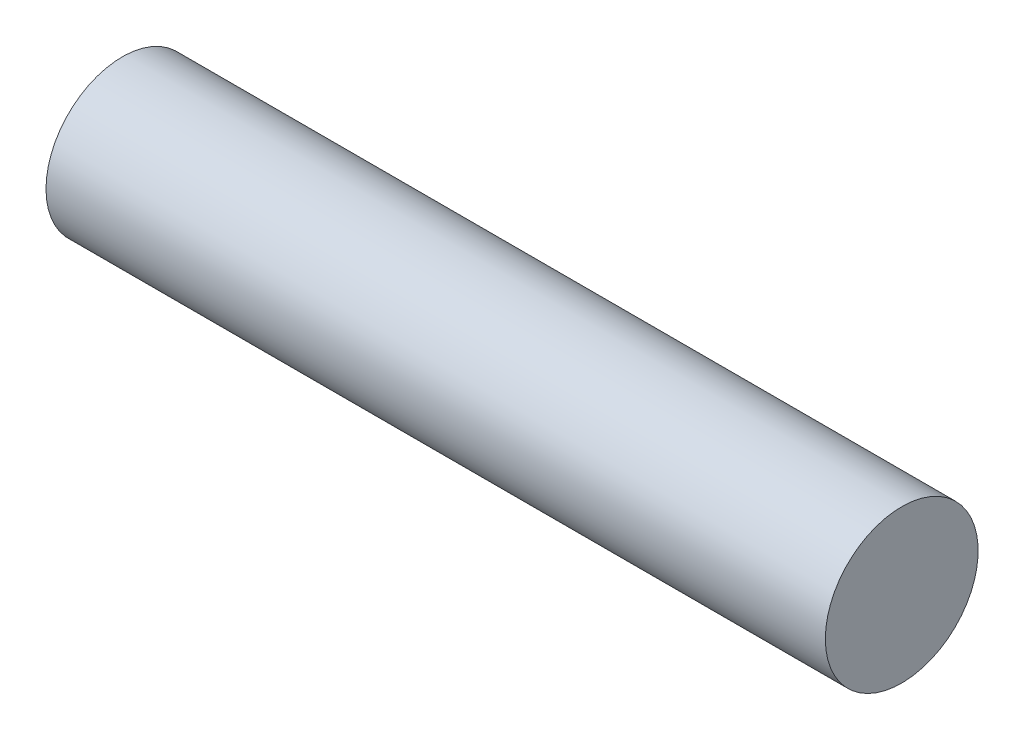
from build123d import *

# Parameters (mm, degrees)
SKETCH1_W = 765
SKETCH1_H = 75


with BuildPart() as part:
    # Sketch1 → Revolve1 (revolve)
    with BuildSketch(Plane.XY):
        with Locations((382.5, 37.5)):
            Rectangle(SKETCH1_W, SKETCH1_H)
    revolve(axis=Axis((0, 0, 0), (1, 0, 0)))


solid = part.part
